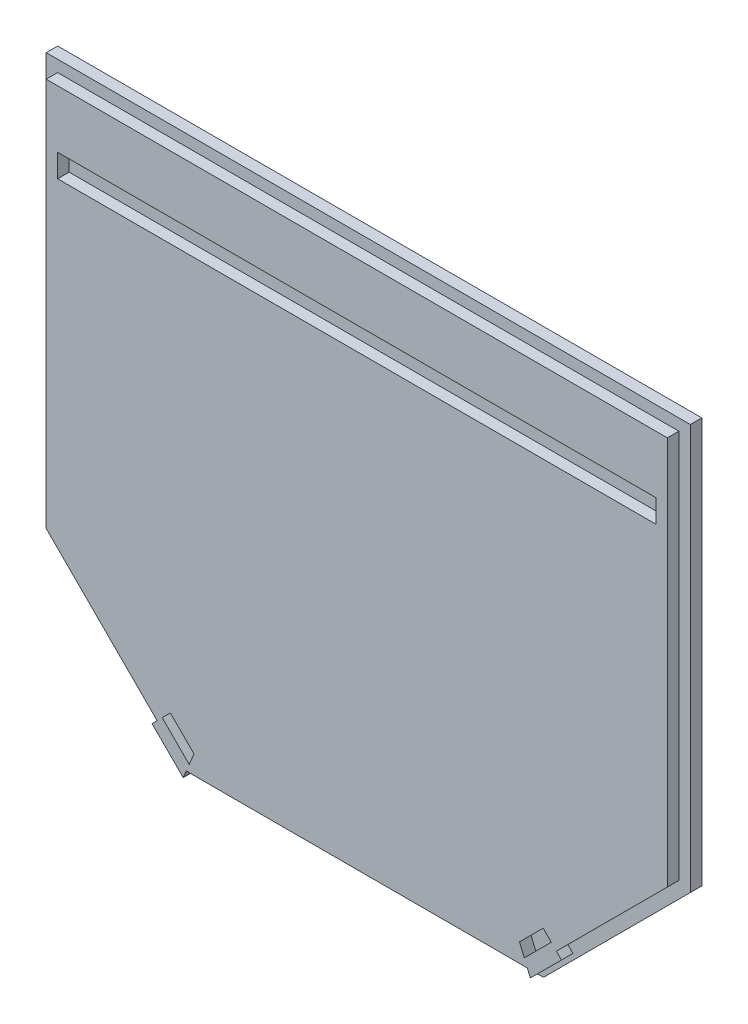
from build123d import *

# Parameters (mm, degrees)
BOSS_EXTRUDE1_DEPTH = 12.7
SKETCH2_W           = 330.2
SKETCH2_H           = 12.7
CUT_EXTRUDE1_DEPTH  = 6.35
CUT_EXTRUDE3_DEPTH  = 6.35


with BuildPart() as part:
    # Sketch1 → Boss-Extrude1 (new body)
    with BuildSketch(Plane.XY):
        Polygon((0, 0), (355.6, 0), (355.6, -223.774), (292.534512242, -286.839487758), (274.574, -304.8), (81.026, -304.8), (63.065487758, -286.839487758), (0, -223.774), align=None)
    extrude(amount=BOSS_EXTRUDE1_DEPTH)

    # Sketch2 → Cut-Extrude1 (cut)
    with BuildSketch(Plane.XY.offset(12.7)):
        Polygon((0, 0), (0, -223.774), (81.026, -304.8), (274.574, -304.8), (355.6, -223.774), (355.6, 0), align=None)
        Polygon((6.35, -221.143743879), (67.607470696, -282.401214575), (64.787670274, -285.221014997), (82.004455277, -302.4378), (83.656256121, -298.45), (271.943743879, -298.45), (273.595544723, -302.4378), (290.812329726, -285.221014997), (287.992529304, -282.401214575), (349.25, -221.143743879), (349.25, -6.35), (6.35, -6.35), align=None, mode=Mode.SUBTRACT)
        with Locations((177.8, -44.45)):
            Rectangle(SKETCH2_W, SKETCH2_H)
    extrude(amount=-CUT_EXTRUDE1_DEPTH, mode=Mode.SUBTRACT)

    # Sketch3 → Cut-Extrude3 (cut)
    with BuildSketch(Plane.XY.offset(12.7)):
        Polygon((85.308056965, -294.4622), (70.400831804, -279.554974839), (74.890959865, -275.064846778), (87.938313086, -288.1122), align=None)
        Polygon((285.199168196, -279.554974839), (280.709040135, -275.064846778), (267.661686914, -288.1122), (270.291943035, -294.4622), align=None)
    extrude(amount=-CUT_EXTRUDE3_DEPTH, mode=Mode.SUBTRACT)


solid = part.part
